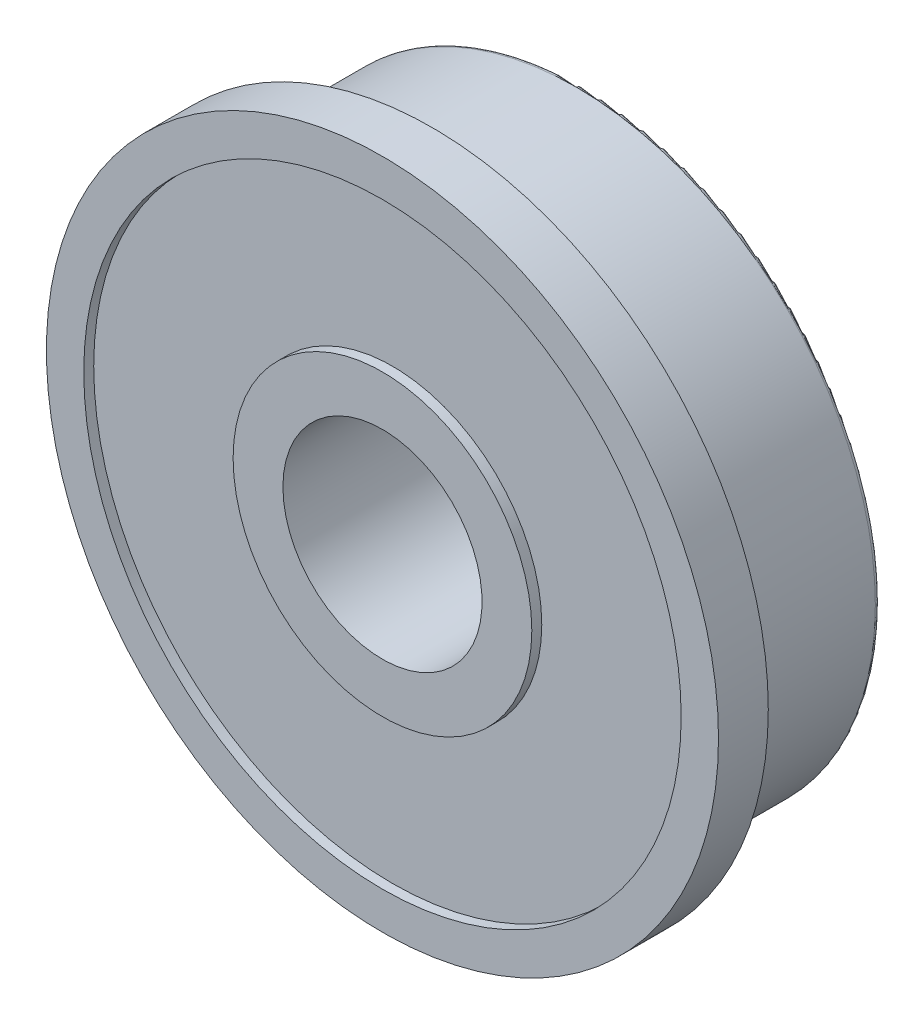
from build123d import *

# Parameters (mm, degrees)
SKETCH_1_R          = 6
EXTRUDE_1_DEPTH     = 4
SKETCH_2_R          = 6.75
EXTRUDE_2_DEPTH     = 1
SKETCH_3_R          = 2
CUT_EXTRUDE_1_DEPTH = 5
SKETCH_4_R          = 5
SKETCH_4_R_2        = 3
CUT_EXTRUDE_2_DEPTH = 0.2
SKETCH_5_R          = 6
SKETCH_5_R_2        = 3
CUT_EXTRUDE_3_DEPTH = 0.2
FILLET_1_R          = 0.1


with BuildPart() as part:
    # 草圖1 → 填料-伸長1 (new body)
    with BuildSketch(Plane.XY):
        Circle(SKETCH_1_R)
    extrude(amount=EXTRUDE_1_DEPTH)

    # 草圖2 → 填料-伸長2 (add)
    with BuildSketch(Plane.XY.offset(4)):
        Circle(SKETCH_2_R)
    extrude(amount=-EXTRUDE_2_DEPTH)

    # 草圖3 → 除料-伸長1 (cut, through all)
    with BuildSketch(Plane(origin=(0, 0, 0), x_dir=(-1, 0, 0), z_dir=(0, 0, -1))):
        Circle(SKETCH_3_R)
    extrude(amount=-CUT_EXTRUDE_1_DEPTH, mode=Mode.SUBTRACT)

    # 草圖4 → 除料-伸長2 (cut)
    with BuildSketch(Plane(origin=(0, 0, 0), x_dir=(-1, 0, 0), z_dir=(0, 0, -1))):
        Circle(SKETCH_4_R)
        Circle(SKETCH_4_R_2, mode=Mode.SUBTRACT)
    extrude(amount=-CUT_EXTRUDE_2_DEPTH, mode=Mode.SUBTRACT)

    # 草圖5 → 除料-伸長3 (cut)
    with BuildSketch(Plane.XY.offset(4)):
        Circle(SKETCH_5_R)
        Circle(SKETCH_5_R_2, mode=Mode.SUBTRACT)
    extrude(amount=-CUT_EXTRUDE_3_DEPTH, mode=Mode.SUBTRACT)

    # 圓角1
    fillet_1_edges = [part.edges().sort_by_distance(p)[0] for p in [
        (-6, 0, 0),
    ]]
    fillet(fillet_1_edges, radius=FILLET_1_R)


solid = part.part
